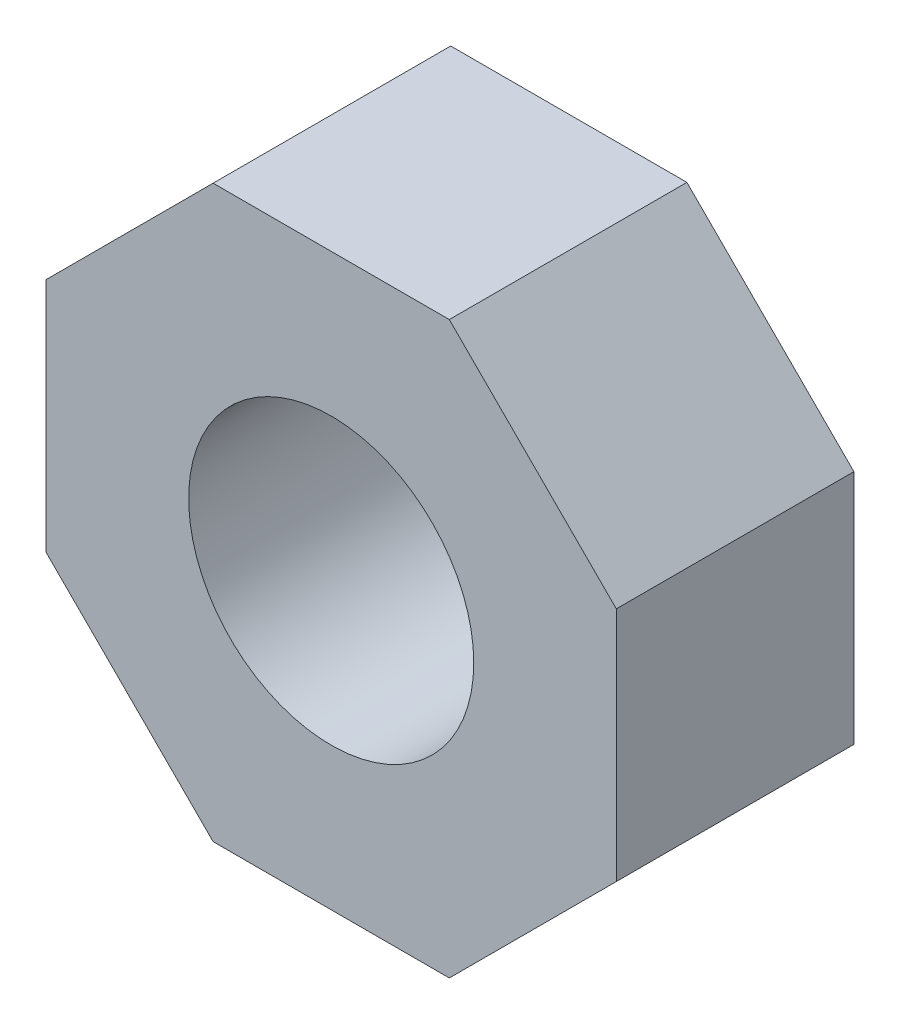
from build123d import *

# Parameters (mm, degrees)
ESQUISSE1_R        = 3
BOSS_EXTRU_1_DEPTH = 5


with BuildPart() as part:
    # Esquisse1 → Boss.-Extru.1 (new body)
    with BuildSketch(Plane.XY):
        Polygon((-2.485281374, 6), (-4.242640687, 4.242640687), (-6, 2.485281374), (-6, 0), (-6, -2.485281374), (-4.242640687, -4.242640687), (-2.485281374, -6), (2.485281374, -6), (4.242640687, -4.242640687), (6, -2.485281374), (6, 2.485281374), (4.242640687, 4.242640687), (2.485281374, 6), align=None)
        Circle(ESQUISSE1_R, mode=Mode.SUBTRACT)
    extrude(amount=BOSS_EXTRU_1_DEPTH)


solid = part.part
